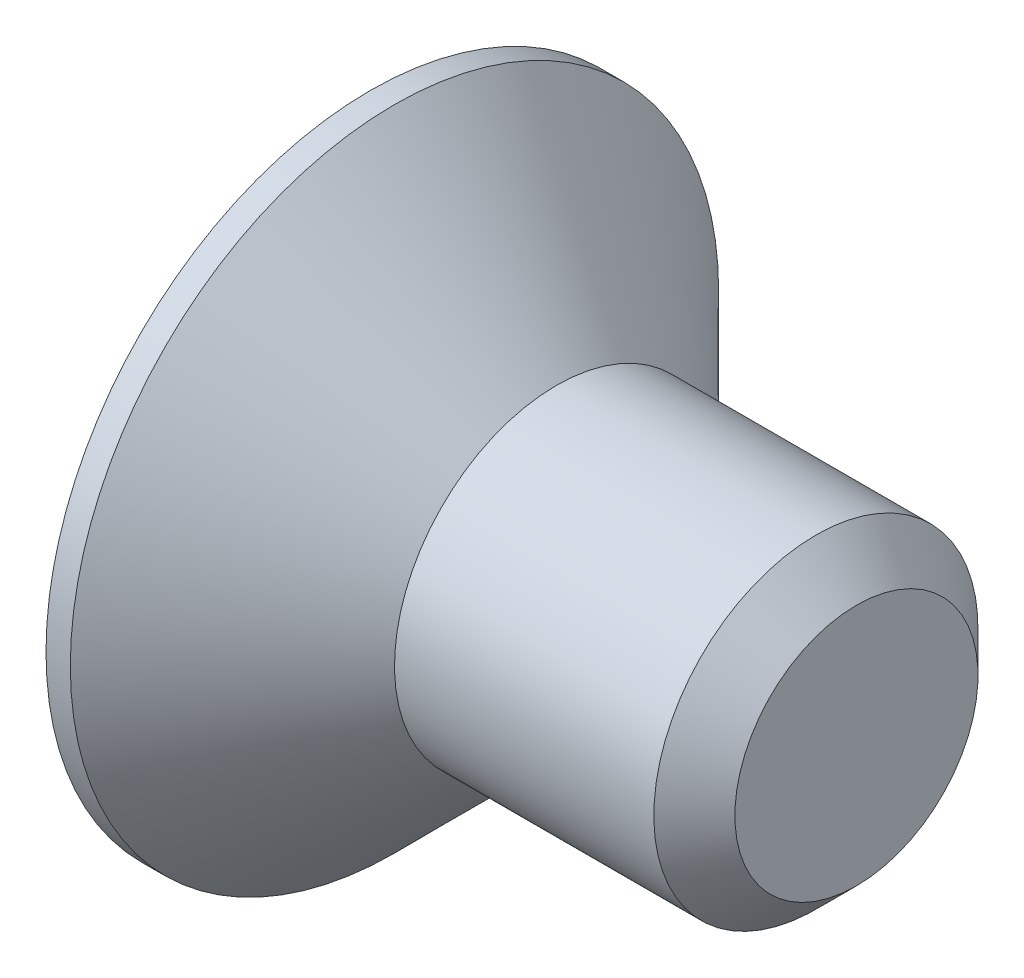
from build123d import *

# Parameters (mm, degrees)
CHANFREIN1_SIZE         = 0.5
ENL_V_MAT_EXTRU_1_DEPTH = 1.8


with BuildPart() as part:
    # Esquisse1 → Révolution1 (revolve)
    with BuildSketch(Plane.XY):
        Polygon((0, 0), (0, 4), (0.3, 4), (2.3, 2), (6, 2), (6, 0), align=None)
    revolve(axis=Axis((6, 0, 0), (-1, 0, 0)))

    # Chanfrein1
    chanfrein1_edges = [part.edges().sort_by_distance(p)[0] for p in [
        (6, -2, 0),
    ]]
    chamfer(chanfrein1_edges, length=CHANFREIN1_SIZE)

    # Esquisse2 → Enlèv. mat.-Extru.1 (cut)
    with BuildSketch(Plane.ZY):
        Polygon((0, 1.443375673), (-1.25, 0.721687836), (-1.25, -0.721687836), (0, -1.443375673), (1.25, -0.721687836), (1.25, 0.721687836), align=None)
    extrude(amount=-ENL_V_MAT_EXTRU_1_DEPTH, mode=Mode.SUBTRACT)


solid = part.part
